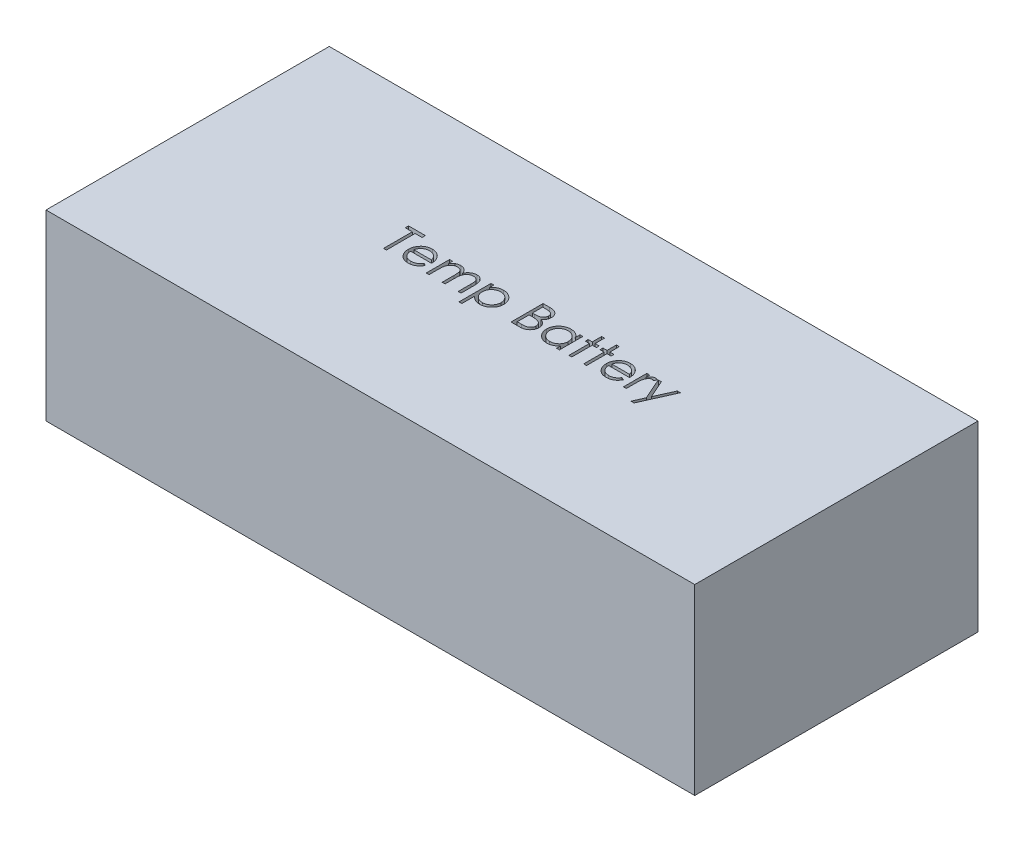
from build123d import *

# Parameters (mm, degrees)
SKETCH1_W           = 71
SKETCH1_H           = 31
BOSS_EXTRUDE1_DEPTH = 20
CUT_EXTRUDE1_DEPTH  = 4


with BuildPart() as part:
    # Sketch1 → Boss-Extrude1 (new body)
    with BuildSketch(Plane(origin=(0, 0, 0), x_dir=(1, 0, 0), z_dir=(0, 1, 0))):
        Rectangle(SKETCH1_W, SKETCH1_H)
    extrude(amount=BOSS_EXTRUDE1_DEPTH)

    # Sketch2 → Cut-Extrude1 (cut)
    with BuildSketch(Plane(origin=(0, 20, 0), x_dir=(1, 0, 0), z_dir=(0, 1, 0))):
        Polygon((-14.152078987, 2.473875698), (-14.152078987, 2.832850057), (-12.312335397, 2.832850057), (-12.312335397, 2.473875698), (-13.07515591, 2.473875698), (-13.07515591, -0.667149943), (-13.389258474, -0.667149943), (-13.389258474, 2.473875698), align=None)
        with BuildLine():
            Line((-9.764458794, 0.140542365), (-9.48541232, -0.00599209))
            add(Edge.make_bspline(
                [(-9.48541232, -0.00599209), (-9.507648915, -0.045435421), (-9.550912524, -0.122176524), (-9.625313271, -0.227608385), (-9.703305344, -0.322456101), (-9.788409312, -0.404185755), (-9.878078991, -0.47543714), (-9.972811646, -0.537774965), (-10.073100464, -0.590893485), (-10.178950188, -0.635646013), (-10.291249739, -0.670055507), (-10.410271256, -0.694359728), (-10.536242751, -0.709382996), (-10.622588931, -0.711128137), (-10.666802544, -0.712021738)],
                knots=[0, 0, 0, 0, 0.000135759, 0.000264133, 0.000386579, 0.000503597, 0.000617365, 0.000729763, 0.000843304, 0.000957371, 0.001074023, 0.001195027, 0.001321389, 0.001453992, 0.001453992, 0.001453992, 0.001453992], degree=3))
            add(Edge.make_bspline(
                [(-10.666802544, -0.712021738), (-10.715944522, -0.710874562), (-10.811806283, -0.708636756), (-10.951346031, -0.689344291), (-11.082725449, -0.657871932), (-11.205937152, -0.613906391), (-11.320679405, -0.556479067), (-11.42718026, -0.486519585), (-11.525999786, -0.40438733), (-11.614023995, -0.309370887), (-11.693267877, -0.20768893), (-11.763193697, -0.101733045), (-11.821651128, 0.008230179), (-11.869203739, 0.121500703), (-11.907608604, 0.237364597), (-11.934375307, 0.356876065), (-11.949805055, 0.479711649), (-11.952169501, 0.562808985), (-11.953361038, 0.604684993)],
                knots=[0, 0, 0, 0, 0.000147371, 0.000287478, 0.000421649, 0.000552053, 0.000679042, 0.000805636, 0.000933558, 0.00106351, 0.001193382, 0.001319977, 0.001443869, 0.001566405, 0.001688128, 0.001809576, 0.001933238, 0.002058864, 0.002058864, 0.002058864, 0.002058864], degree=3))
            add(Edge.make_bspline(
                [(-11.953361038, 0.604684993), (-11.952301896, 0.643979824), (-11.950202818, 0.721856988), (-11.936972031, 0.837122533), (-11.913523738, 0.949150985), (-11.881347414, 1.058035433), (-11.839796168, 1.163593567), (-11.788963948, 1.265889631), (-11.728771571, 1.364814771), (-11.682298897, 1.427217904), (-11.658889884, 1.458651339)],
                knots=[0, 0, 0, 0, 0.000117891, 0.000233644, 0.000347498, 0.000460856, 0.000573868, 0.000687374, 0.000803169, 0.000920699, 0.000920699, 0.000920699, 0.000920699], degree=3))
            add(Edge.make_bspline(
                [(-11.658889884, 1.458651339), (-11.627182201, 1.496520209), (-11.564771255, 1.57105836), (-11.459214899, 1.668996686), (-11.344914703, 1.751040461), (-11.223303077, 1.819047597), (-11.092966603, 1.870721244), (-10.955657312, 1.909228826), (-10.809811725, 1.930806837), (-10.710106505, 1.933854671), (-10.659090204, 1.93541416)],
                knots=[0, 0, 0, 0, 0.000148071, 0.000291452, 0.00043058, 0.000569298, 0.000708346, 0.00085021, 0.000996268, 0.001149307, 0.001149307, 0.001149307, 0.001149307], degree=3))
            add(Edge.make_bspline(
                [(-10.659090204, 1.93541416), (-10.606642599, 1.934060111), (-10.503752353, 1.931403776), (-10.353720232, 1.906777442), (-10.211759516, 1.867724888), (-10.077927011, 1.812571097), (-9.952209151, 1.741411545), (-9.835423101, 1.653269704), (-9.725571588, 1.550851617), (-9.66166301, 1.472088407), (-9.629142288, 1.432008711)],
                knots=[0, 0, 0, 0, 0.000157241, 0.00030847, 0.000454763, 0.000598116, 0.000741606, 0.000886879, 0.001036172, 0.001190853, 0.001190853, 0.001190853, 0.001190853], degree=3))
            add(Edge.make_bspline(
                [(-9.629142288, 1.432008711), (-9.607015349, 1.40180513), (-9.562908756, 1.341599011), (-9.507661656, 1.243427854), (-9.459704261, 1.14071726), (-9.4213713, 1.031806962), (-9.390331799, 0.917987382), (-9.36787498, 0.798444838), (-9.354705362, 0.673214926), (-9.352116664, 0.587888371), (-9.350796935, 0.544388519)],
                knots=[0, 0, 0, 0, 0.000112234, 0.000223721, 0.000337279, 0.000451932, 0.000569628, 0.000690912, 0.000816421, 0.00094695, 0.00094695, 0.00094695, 0.00094695], degree=3))
            Line((-9.350796935, 0.544388519), (-11.639258474, 0.544388519))
            add(Edge.make_bspline(
                [(-11.639258474, 0.544388519), (-11.637718867, 0.510688055), (-11.634691293, 0.444417451), (-11.62057615, 0.347446668), (-11.598327376, 0.255073326), (-11.567058314, 0.167990284), (-11.529191468, 0.085060156), (-11.482805752, 0.006898119), (-11.427466198, -0.066139811), (-11.365740498, -0.134706949), (-11.297033403, -0.19576771), (-11.224750656, -0.250419486), (-11.147857091, -0.296225083), (-11.066959007, -0.333404972), (-10.982187222, -0.362511288), (-10.893515027, -0.382379109), (-10.801116911, -0.395686216), (-10.738131177, -0.397165881), (-10.706065365, -0.397919174)],
                knots=[0, 0, 0, 0, 0.000101159, 0.000198924, 0.000293472, 0.000385722, 0.000476069, 0.000566611, 0.000657757, 0.000750573, 0.000842919, 0.000933083, 0.001022062, 0.001110842, 0.001199752, 0.001290403, 0.001383113, 0.001479259, 0.001479259, 0.001479259, 0.001479259], degree=3))
            add(Edge.make_bspline(
                [(-10.706065365, -0.397919174), (-10.674714217, -0.397311117), (-10.612507526, -0.396104616), (-10.519866669, -0.384372705), (-10.428727141, -0.365402429), (-10.339466158, -0.339512439), (-10.253895312, -0.307935587), (-10.174649762, -0.269832729), (-10.101769547, -0.227682983), (-10.03365258, -0.179473308), (-9.967581587, -0.120465121), (-9.9020391, -0.0468294), (-9.831762447, 0.040258128), (-9.787772854, 0.105803794), (-9.764458794, 0.140542365)],
                knots=[0, 0, 0, 0, 9.4016e-05, 0.000186545, 0.000279636, 0.000373054, 0.000465125, 0.000552934, 0.000636508, 0.000717442, 0.000802858, 0.000901616, 0.001012865, 0.001138311, 0.001138311, 0.001138311, 0.001138311], degree=3))
        make_face()
        with BuildLine():
            add(Edge.make_bspline(
                [(-9.664899499, 0.858491083), (-9.676396124, 0.900153957), (-9.698523425, 0.980341577), (-9.74475979, 1.091382468), (-9.796831331, 1.190070369), (-9.858453062, 1.275650002), (-9.928271788, 1.351653515), (-10.00891697, 1.4180721), (-10.099352864, 1.477489551), (-10.199112004, 1.52764205), (-10.304753789, 1.570331909), (-10.415359981, 1.598957025), (-10.528217769, 1.618566567), (-10.604552056, 1.620392676), (-10.642964403, 1.621311596)],
                knots=[0, 0, 0, 0, 0.000129543, 0.000249328, 0.000360065, 0.000463575, 0.000564789, 0.000668832, 0.000776175, 0.000888744, 0.001003316, 0.001117263, 0.001230914, 0.001346035, 0.001346035, 0.001346035, 0.001346035], degree=3))
            add(Edge.make_bspline(
                [(-10.642964403, 1.621311596), (-10.674313842, 1.620699924), (-10.736285091, 1.619490778), (-10.827586159, 1.608020649), (-10.915265858, 1.589060804), (-10.999971145, 1.563095847), (-11.080592014, 1.528487245), (-11.158786782, 1.487904018), (-11.232567178, 1.438362434), (-11.278708474, 1.40060358), (-11.30201889, 1.381527942)],
                knots=[0, 0, 0, 0, 9.4016e-05, 0.000185849, 0.000275511, 0.000362884, 0.000451173, 0.00053836, 0.000626838, 0.000717174, 0.000717174, 0.000717174, 0.000717174], degree=3))
            add(Edge.make_bspline(
                [(-11.30201889, 1.381527942), (-11.318712172, 1.366433626), (-11.352495307, 1.33588641), (-11.397635828, 1.283257204), (-11.440856301, 1.226505641), (-11.480189953, 1.163460517), (-11.51626754, 1.094839738), (-11.550027517, 1.021222103), (-11.580413929, 0.942048972), (-11.597510039, 0.886876533), (-11.606305749, 0.858491083)],
                knots=[0, 0, 0, 0, 6.7454e-05, 0.00013651, 0.000207604, 0.000281328, 0.000359112, 0.000440057, 0.000524171, 0.000613305, 0.000613305, 0.000613305, 0.000613305], degree=3))
            Line((-11.606305749, 0.858491083), (-9.664899499, 0.858491083))
        make_face(mode=Mode.SUBTRACT)
        with BuildLine():
            Line((-8.722591807, 1.890542365), (-8.408489243, 1.890542365))
            Line((-8.408489243, 1.890542365), (-8.408489243, 1.446031147))
            add(Edge.make_bspline(
                [(-8.408489243, 1.446031147), (-8.380205293, 1.484918749), (-8.326010533, 1.559431122), (-8.237144881, 1.657621406), (-8.148368768, 1.740949561), (-8.084435387, 1.784692432), (-8.053721615, 1.805706628)],
                knots=[0, 0, 0, 0, 0.000144152, 0.000276209, 0.000396804, 0.000508302, 0.000508302, 0.000508302, 0.000508302], degree=3))
            add(Edge.make_bspline(
                [(-8.053721615, 1.805706628), (-8.011856953, 1.825711993), (-7.928859053, 1.865373206), (-7.797439828, 1.905606765), (-7.662965158, 1.930331867), (-7.572156944, 1.93371324), (-7.526478025, 1.93541416)],
                knots=[0, 0, 0, 0, 0.000139031, 0.000275633, 0.000410962, 0.000547939, 0.000547939, 0.000547939, 0.000547939], degree=3))
            add(Edge.make_bspline(
                [(-7.526478025, 1.93541416), (-7.495585028, 1.934368869), (-7.434449449, 1.932300295), (-7.343865359, 1.91884026), (-7.256006747, 1.895574087), (-7.171392718, 1.863166763), (-7.091672039, 1.823920076), (-7.018582841, 1.777870368), (-6.952958633, 1.726173292), (-6.894832582, 1.666494359), (-6.842563556, 1.597157761), (-6.79448471, 1.516293512), (-6.750059497, 1.422085851), (-6.725438188, 1.35371931), (-6.712475621, 1.317725859)],
                knots=[0, 0, 0, 0, 9.2678e-05, 0.000183405, 0.000274048, 0.000364807, 0.000454797, 0.00054019, 0.000623517, 0.000704829, 0.000789387, 0.000883415, 0.000986597, 0.001101318, 0.001101318, 0.001101318, 0.001101318], degree=3))
            add(Edge.make_bspline(
                [(-6.712475621, 1.317725859), (-6.69876437, 1.342450278), (-6.671782553, 1.391104463), (-6.626476916, 1.459962725), (-6.579009119, 1.524369517), (-6.528974626, 1.584375941), (-6.476550039, 1.639685672), (-6.421488639, 1.690481573), (-6.364103857, 1.736981787), (-6.284311618, 1.791304946), (-6.18049901, 1.849006128), (-6.049610895, 1.899034572), (-5.913460724, 1.9299507), (-5.821043026, 1.933580973), (-5.77437466, 1.93541416)],
                knots=[0, 0, 0, 0, 8.4789e-05, 0.000166854, 0.000247064, 0.000324714, 0.000401089, 0.000475513, 0.000549314, 0.000622436, 0.0007649, 0.000904487, 0.001041601, 0.001181469, 0.001181469, 0.001181469, 0.001181469], degree=3))
            add(Edge.make_bspline(
                [(-5.77437466, 1.93541416), (-5.731493197, 1.933796939), (-5.647570011, 1.930631881), (-5.525392745, 1.905778407), (-5.411450939, 1.86310076), (-5.305973863, 1.804867124), (-5.21081405, 1.73168794), (-5.128097741, 1.644619103), (-5.058327377, 1.54427648), (-5.012748738, 1.449884491), (-4.981833473, 1.366549158), (-4.962772239, 1.295542867), (-4.945932544, 1.217391314), (-4.931951299, 1.132001053), (-4.921732747, 1.039070444), (-4.914162031, 0.938751568), (-4.909037958, 0.830966457), (-4.908675885, 0.756600956), (-4.908489243, 0.718266724)],
                knots=[0, 0, 0, 0, 0.000128581, 0.000251645, 0.00037211, 0.000492305, 0.000611786, 0.000730807, 0.000851198, 0.000976936, 0.001044145, 0.001117629, 0.001197252, 0.00128393, 0.001377074, 0.001477631, 0.001585715, 0.001700707, 0.001700707, 0.001700707, 0.001700707], degree=3))
            Line((-4.908489243, 0.718266724), (-4.908489243, -0.667149943))
            Line((-4.908489243, -0.667149943), (-5.222591807, -0.667149943))
            Line((-5.222591807, -0.667149943), (-5.222591807, 0.719668968))
            add(Edge.make_bspline(
                [(-5.222591807, 0.719668968), (-5.22266969, 0.752389541), (-5.222819369, 0.815273508), (-5.225513001, 0.90552596), (-5.230588315, 0.987794317), (-5.236522954, 1.061966405), (-5.244766763, 1.128215193), (-5.255412695, 1.186407612), (-5.266690375, 1.237001423), (-5.285426366, 1.293087471), (-5.315374257, 1.354957681), (-5.360991737, 1.421681257), (-5.418461844, 1.479762057), (-5.484822, 1.530180374), (-5.560370445, 1.571174015), (-5.643635168, 1.600450025), (-5.73409922, 1.618572903), (-5.796722008, 1.620378919), (-5.82906216, 1.621311596)],
                knots=[0, 0, 0, 0, 9.816e-05, 0.000188648, 0.000270826, 0.000345412, 0.000411852, 0.000470988, 0.000522857, 0.0005672, 0.000648106, 0.000728233, 0.000808554, 0.000892128, 0.000977461, 0.001065278, 0.001156029, 0.001252946, 0.001252946, 0.001252946, 0.001252946], degree=3))
            add(Edge.make_bspline(
                [(-5.82906216, 1.621311596), (-5.868732114, 1.619895438), (-5.947135025, 1.617096573), (-6.061580511, 1.5885227), (-6.171551528, 1.545442449), (-6.273766661, 1.483009992), (-6.367794451, 1.408201628), (-6.448694029, 1.319252033), (-6.515526215, 1.218622106), (-6.560780191, 1.125475403), (-6.589369492, 1.041805959), (-6.608246408, 0.968708587), (-6.622929799, 0.88562702), (-6.636700329, 0.793119529), (-6.645688057, 0.690549348), (-6.653856429, 0.578390947), (-6.657677292, 0.456306988), (-6.65821175, 0.371680299), (-6.658489243, 0.327741884)],
                knots=[0, 0, 0, 0, 0.000118788, 0.00023477, 0.000351815, 0.000471937, 0.000592603, 0.000711217, 0.000831002, 0.000953929, 0.001020668, 0.001096002, 0.00118016, 0.001273662, 0.001376495, 0.001488939, 0.001611007, 0.001742825, 0.001742825, 0.001742825, 0.001742825], degree=3))
            Line((-6.658489243, 0.327741884), (-6.658489243, -0.667149943))
            Line((-6.658489243, -0.667149943), (-6.972591807, -0.667149943))
            Line((-6.972591807, -0.667149943), (-6.972591807, 0.633430987))
            add(Edge.make_bspline(
                [(-6.972591807, 0.633430987), (-6.972671238, 0.670124306), (-6.972824055, 0.740718563), (-6.975500373, 0.841952238), (-6.980586994, 0.934033318), (-6.986467543, 1.016854782), (-6.994927721, 1.090266111), (-7.004537483, 1.154660869), (-7.015886094, 1.20987762), (-7.034675978, 1.270441005), (-7.063390447, 1.337161928), (-7.109578709, 1.408302949), (-7.167186289, 1.470571046), (-7.234757165, 1.523729795), (-7.310762847, 1.567671276), (-7.394746248, 1.599331028), (-7.485951161, 1.617755317), (-7.548828867, 1.620103814), (-7.581165525, 1.621311596)],
                knots=[0, 0, 0, 0, 0.000110078, 0.00021178, 0.000303758, 0.00038673, 0.000460827, 0.00052538, 0.000582037, 0.000629718, 0.00071543, 0.000799052, 0.000882908, 0.000968755, 0.001056067, 0.001145266, 0.001236843, 0.001333803, 0.001333803, 0.001333803, 0.001333803], degree=3))
            add(Edge.make_bspline(
                [(-7.581165525, 1.621311596), (-7.619181736, 1.619781136), (-7.694946696, 1.616730983), (-7.806248665, 1.589276709), (-7.913734349, 1.546272635), (-8.015689048, 1.486612816), (-8.109363196, 1.412713737), (-8.191371463, 1.325798841), (-8.260313989, 1.226949808), (-8.306045804, 1.134785291), (-8.335544278, 1.053212016), (-8.355139613, 0.983861069), (-8.371979239, 0.90686082), (-8.38449326, 0.821973709), (-8.396573676, 0.729752615), (-8.402403985, 0.629738125), (-8.408075547, 0.522016038), (-8.408347962, 0.447643492), (-8.408489243, 0.409072012)],
                knots=[0, 0, 0, 0, 0.000113893, 0.000226985, 0.000341817, 0.000460265, 0.000580056, 0.000698595, 0.000817435, 0.000940348, 0.001005999, 0.001077458, 0.001156396, 0.001242271, 0.001334801, 0.001435306, 0.00154269, 0.001658383, 0.001658383, 0.001658383, 0.001658383], degree=3))
            Line((-8.408489243, 0.409072012), (-8.408489243, -0.667149943))
            Line((-8.408489243, -0.667149943), (-8.722591807, -0.667149943))
            Line((-8.722591807, -0.667149943), (-8.722591807, 1.890542365))
        make_face()
        with BuildLine():
            Line((-4.190540525, 1.890542365), (-3.876437961, 1.890542365))
            Line((-3.876437961, 1.890542365), (-3.876437961, 1.417285153))
            add(Edge.make_bspline(
                [(-3.876437961, 1.417285153), (-3.843080477, 1.460222887), (-3.778256882, 1.54366378), (-3.666531977, 1.651653909), (-3.548605168, 1.742729212), (-3.421441756, 1.814111745), (-3.287018066, 1.867932557), (-3.145885748, 1.907712007), (-2.996846983, 1.931153482), (-2.894950531, 1.933975143), (-2.842984435, 1.93541416)],
                knots=[0, 0, 0, 0, 0.00016294, 0.00031664, 0.000464722, 0.000608822, 0.000752559, 0.000898176, 0.001047911, 0.001203751, 0.001203751, 0.001203751, 0.001203751], degree=3))
            add(Edge.make_bspline(
                [(-2.842984435, 1.93541416), (-2.797592832, 1.934100981), (-2.707873944, 1.931505414), (-2.575810715, 1.913932359), (-2.448635331, 1.883814667), (-2.327067277, 1.840413752), (-2.209804212, 1.786758282), (-2.098582112, 1.719041246), (-1.991668557, 1.640635055), (-1.891752368, 1.550402904), (-1.799431, 1.452774638), (-1.719584819, 1.347752334), (-1.650712915, 1.238789747), (-1.595042618, 1.124197655), (-1.551434271, 1.004878425), (-1.520419593, 0.880349984), (-1.50196195, 0.751074044), (-1.499485498, 0.663171323), (-1.498232833, 0.618707429)],
                knots=[0, 0, 0, 0, 0.000136164, 0.000269135, 0.000398888, 0.000527501, 0.000655799, 0.000785059, 0.000917435, 0.001052984, 0.001188402, 0.001319939, 0.001448139, 0.001574506, 0.001701376, 0.001828571, 0.001958859, 0.002092222, 0.002092222, 0.002092222, 0.002092222], degree=3))
            add(Edge.make_bspline(
                [(-1.498232833, 0.618707429), (-1.499458318, 0.573305121), (-1.501875153, 0.483765216), (-1.520620159, 0.352278119), (-1.550577033, 0.225790745), (-1.593635216, 0.104513481), (-1.649276704, -0.01147017), (-1.716981265, -0.122076566), (-1.796867732, -0.227270269), (-1.888168859, -0.325623169), (-1.987221795, -0.416222482), (-2.093099285, -0.495460552), (-2.20415821, -0.562001927), (-2.319830378, -0.617584887), (-2.441106016, -0.659477071), (-2.567419294, -0.689694871), (-2.69870144, -0.708329367), (-2.788002592, -0.710781509), (-2.83316873, -0.712021738)],
                knots=[0, 0, 0, 0, 0.000136164, 0.000268535, 0.000397606, 0.000525558, 0.00065382, 0.000782843, 0.000913955, 0.001049409, 0.001184907, 0.001316158, 0.001445417, 0.001572744, 0.001700463, 0.001829535, 0.001961906, 0.002097369, 0.002097369, 0.002097369, 0.002097369], degree=3))
            add(Edge.make_bspline(
                [(-2.83316873, -0.712021738), (-2.883996302, -0.71072693), (-2.984395658, -0.708169305), (-3.131193329, -0.682249895), (-3.27247018, -0.643512959), (-3.406661005, -0.586813966), (-3.534828818, -0.51455845), (-3.656248623, -0.426448244), (-3.771565376, -0.322667619), (-3.840974134, -0.243935803), (-3.876437961, -0.203708436)],
                knots=[0, 0, 0, 0, 0.000152339, 0.000300914, 0.000445856, 0.000591043, 0.000736709, 0.000886352, 0.001040245, 0.001201023, 0.001201023, 0.001201023, 0.001201023], degree=3))
            Line((-3.876437961, -0.203708436), (-3.876437961, -1.609457635))
            Line((-3.876437961, -1.609457635), (-4.190540525, -1.609457635))
            Line((-4.190540525, -1.609457635), (-4.190540525, 1.890542365))
        make_face()
        with BuildLine():
            add(Edge.make_bspline(
                [(-2.845788922, 1.621311596), (-2.881368485, 1.620671338), (-2.951415473, 1.619410834), (-3.054087692, 1.604436885), (-3.152983119, 1.582699144), (-3.247105071, 1.549787244), (-3.337355687, 1.509388431), (-3.423039852, 1.45890642), (-3.50409742, 1.399254414), (-3.58032445, 1.33157507), (-3.649187743, 1.257000382), (-3.710150671, 1.177412573), (-3.761357977, 1.092912433), (-3.803859997, 1.00428707), (-3.836203279, 0.910841785), (-3.859158999, 0.813108773), (-3.873589352, 0.71098106), (-3.875478289, 0.641425054), (-3.876437961, 0.606087237)],
                knots=[0, 0, 0, 0, 0.000106654, 0.000209973, 0.000310662, 0.000409994, 0.000508521, 0.000606883, 0.00070771, 0.000810012, 0.000912217, 0.001011779, 0.001110258, 0.001208104, 0.001306111, 0.001406276, 0.001508901, 0.001614884, 0.001614884, 0.001614884, 0.001614884], degree=3))
            add(Edge.make_bspline(
                [(-3.876437961, 0.606087237), (-3.874847105, 0.559699124), (-3.871730483, 0.468820883), (-3.846393115, 0.336036761), (-3.805157851, 0.210385106), (-3.746629137, 0.092924069), (-3.672681563, -0.015058767), (-3.583583407, -0.111749373), (-3.480140856, -0.196539964), (-3.364073664, -0.267961218), (-3.239651533, -0.325949284), (-3.109865621, -0.367463495), (-2.97650074, -0.393035723), (-2.886332421, -0.396282542), (-2.84088107, -0.397919174)],
                knots=[0, 0, 0, 0, 0.000139077, 0.000272463, 0.00040394, 0.000534691, 0.000664794, 0.000795295, 0.000927798, 0.001064768, 0.001203104, 0.001338581, 0.001472656, 0.001608934, 0.001608934, 0.001608934, 0.001608934], degree=3))
            add(Edge.make_bspline(
                [(-2.84088107, -0.397919174), (-2.796345302, -0.396362797), (-2.707949809, -0.393273668), (-2.577791687, -0.366535481), (-2.451301049, -0.325690456), (-2.331120877, -0.2661309), (-2.218297389, -0.193140842), (-2.116415835, -0.105580809), (-2.027408922, -0.004090865), (-1.951544567, 0.108917638), (-1.890413081, 0.230093021), (-1.844482841, 0.35547441), (-1.817974268, 0.484619833), (-1.81421748, 0.571617546), (-1.812335397, 0.61520182)],
                knots=[0, 0, 0, 0, 0.000133479, 0.000264931, 0.000397073, 0.000531279, 0.000666044, 0.000799279, 0.000932907, 0.001069805, 0.001206515, 0.001339137, 0.001469351, 0.001600078, 0.001600078, 0.001600078, 0.001600078], degree=3))
            add(Edge.make_bspline(
                [(-1.812335397, 0.61520182), (-1.813790131, 0.659056809), (-1.816688264, 0.746425113), (-1.845235302, 0.875188016), (-1.88813528, 1.001075992), (-1.950694332, 1.120596542), (-2.024895601, 1.233370624), (-2.114642598, 1.332924503), (-2.215258795, 1.420095176), (-2.327947959, 1.492110586), (-2.448888384, 1.549396081), (-2.5762033, 1.59127972), (-2.709246902, 1.616453469), (-2.799874557, 1.619677976), (-2.845788922, 1.621311596)],
                knots=[0, 0, 0, 0, 0.000131379, 0.000261735, 0.000393889, 0.000529349, 0.000665274, 0.000797853, 0.0009301, 0.001063514, 0.001197743, 0.001330552, 0.001464627, 0.001602305, 0.001602305, 0.001602305, 0.001602305], degree=3))
        make_face(mode=Mode.SUBTRACT)
        with BuildLine():
            Line((0.565869731, 2.832850057), (1.24876236, 2.832850057))
            add(Edge.make_bspline(
                [(1.24876236, 2.832850057), (1.282190838, 2.832674307), (1.346983548, 2.832333659), (1.44120299, 2.827050528), (1.529451801, 2.819846858), (1.611755573, 2.808416765), (1.688076275, 2.794624988), (1.758643913, 2.777923172), (1.823234085, 2.757896558), (1.900346821, 2.726050277), (1.988267482, 2.678727109), (2.083465875, 2.608798544), (2.164870114, 2.52326608), (2.235056431, 2.426783425), (2.290857551, 2.320647653), (2.331226848, 2.207388464), (2.356784724, 2.088466723), (2.359413158, 2.006823545), (2.360741526, 1.965562397)],
                knots=[0, 0, 0, 0, 0.00010027, 0.000194349, 0.000283026, 0.000365821, 0.000443519, 0.000515622, 0.000583254, 0.00064614, 0.000765662, 0.000881909, 0.000998927, 0.001118415, 0.001238844, 0.00135727, 0.001478274, 0.001601912, 0.001601912, 0.001601912, 0.001601912], degree=3))
            add(Edge.make_bspline(
                [(2.360741526, 1.965562397), (2.359648308, 1.926909841), (2.357500031, 1.850953924), (2.336957271, 1.739859815), (2.304796603, 1.634108596), (2.260091354, 1.534086211), (2.201989357, 1.442052598), (2.133131039, 1.357265332), (2.050054236, 1.283314275), (1.987810996, 1.241971372), (1.956194251, 1.220971051)],
                knots=[0, 0, 0, 0, 0.000115857, 0.00022767, 0.000337672, 0.000446877, 0.000555233, 0.000663318, 0.000773539, 0.000887324, 0.000887324, 0.000887324, 0.000887324], degree=3))
            add(Edge.make_bspline(
                [(1.956194251, 1.220971051), (1.995954678, 1.205706052), (2.072026226, 1.176500328), (2.176712238, 1.124864864), (2.266907083, 1.068702753), (2.343304229, 1.007370903), (2.408641884, 0.941262092), (2.465694826, 0.869406978), (2.5143762, 0.79086822), (2.556089123, 0.706464685), (2.588637879, 0.617058216), (2.613013784, 0.52348744), (2.626981233, 0.426087885), (2.628968874, 0.359802506), (2.629972296, 0.326339641)],
                knots=[0, 0, 0, 0, 0.000127722, 0.000244363, 0.000349599, 0.000445847, 0.000537565, 0.000627901, 0.000720503, 0.000814257, 0.000909859, 0.001005428, 0.001103887, 0.001204268, 0.001204268, 0.001204268, 0.001204268], degree=3))
            add(Edge.make_bspline(
                [(2.629972296, 0.326339641), (2.62899545, 0.292172768), (2.627073478, 0.22494849), (2.612893506, 0.126193356), (2.588884399, 0.031818409), (2.555813252, -0.058786773), (2.512650938, -0.145446908), (2.460122974, -0.228260172), (2.39749141, -0.306394503), (2.327428541, -0.380718126), (2.248166395, -0.447545913), (2.162650641, -0.50706162), (2.069804321, -0.556007682), (1.971152327, -0.597123703), (1.865588011, -0.628530902), (1.753585403, -0.650503476), (1.635241101, -0.665308513), (1.55403135, -0.666525718), (1.512384155, -0.667149943)],
                knots=[0, 0, 0, 0, 0.000102481, 0.000201635, 0.000298562, 0.000394165, 0.000490425, 0.000588455, 0.000687769, 0.000790423, 0.000894381, 0.000998232, 0.001102369, 0.001208616, 0.001318415, 0.001432129, 0.001550749, 0.00167562, 0.00167562, 0.00167562, 0.00167562], degree=3))
            Line((1.512384155, -0.667149943), (0.565869731, -0.667149943))
            Line((0.565869731, -0.667149943), (0.565869731, 2.832850057))
        make_face()
        with BuildLine():
            Line((0.879972296, 2.473875698), (0.879972296, 1.352080826))
            Line((0.879972296, 1.352080826), (1.091009956, 1.352080826))
            add(Edge.make_bspline(
                [(1.091009956, 1.352080826), (1.121858751, 1.35248075), (1.18146491, 1.353253482), (1.267784807, 1.355466999), (1.347909825, 1.361665043), (1.421701658, 1.367861305), (1.489044102, 1.377935892), (1.549787964, 1.389928015), (1.604886561, 1.40261092), (1.668426106, 1.424180407), (1.740499055, 1.456058083), (1.817332159, 1.505529919), (1.885066628, 1.564454272), (1.942263816, 1.632445234), (1.989075287, 1.707311419), (2.021589002, 1.7878583), (2.043636286, 1.872078432), (2.045627817, 1.929896685), (2.046638962, 1.959252301)],
                knots=[0, 0, 0, 0, 9.2559e-05, 0.000178842, 0.000258967, 0.000333616, 0.000400942, 0.000463093, 0.000519379, 0.000570374, 0.000664201, 0.000755025, 0.000843472, 0.000932526, 0.001020669, 0.001107124, 0.001192318, 0.001280185, 0.001280185, 0.001280185, 0.001280185], degree=3))
            add(Edge.make_bspline(
                [(2.046638962, 1.959252301), (2.046112782, 1.978678072), (2.045080622, 2.016783844), (2.03662732, 2.072333199), (2.022259745, 2.124576951), (2.003805452, 2.174231061), (1.978016763, 2.219742912), (1.9476533, 2.262686107), (1.91096761, 2.301598226), (1.869210297, 2.337967724), (1.821201674, 2.370212252), (1.766970382, 2.398453015), (1.705782705, 2.421193792), (1.63866985, 2.441109944), (1.564598763, 2.455098238), (1.484424209, 2.466751626), (1.39748949, 2.472684368), (1.337344388, 2.473469731), (1.306254347, 2.473875698)],
                knots=[0, 0, 0, 0, 5.8261e-05, 0.000114285, 0.000168029, 0.000220632, 0.000272728, 0.000324483, 0.000378062, 0.000432741, 0.000490301, 0.000551137, 0.000615721, 0.000685833, 0.000760908, 0.00084162, 0.000928788, 0.00102206, 0.00102206, 0.00102206, 0.00102206], degree=3))
            Line((1.306254347, 2.473875698), (0.879972296, 2.473875698))
        make_face(mode=Mode.SUBTRACT)
        with BuildLine():
            Line((0.879972296, 0.993106468), (0.879972296, -0.308175584))
            Line((0.879972296, -0.308175584), (1.327288001, -0.308175584))
            add(Edge.make_bspline(
                [(1.327288001, -0.308175584), (1.359306927, -0.307791836), (1.421019185, -0.307052214), (1.510120415, -0.304637659), (1.592703519, -0.299145384), (1.668391655, -0.290499534), (1.738002107, -0.281121085), (1.80069981, -0.268509804), (1.856993004, -0.254060843), (1.922267312, -0.231726671), (1.99577082, -0.1970302), (2.074981676, -0.144715974), (2.145407894, -0.082392666), (2.205213154, -0.010261752), (2.254226142, 0.068169575), (2.289881597, 0.151314925), (2.311872454, 0.237800453), (2.314534623, 0.296767165), (2.315869731, 0.326339641)],
                knots=[0, 0, 0, 0, 9.6064e-05, 0.000185151, 0.000267373, 0.000344257, 0.000413665, 0.000478015, 0.000536005, 0.000587888, 0.000684801, 0.000778918, 0.000871787, 0.000965866, 0.001059062, 0.00114827, 0.001236355, 0.001324974, 0.001324974, 0.001324974, 0.001324974], degree=3))
            add(Edge.make_bspline(
                [(2.315869731, 0.326339641), (2.315593627, 0.344832981), (2.315045872, 0.381521363), (2.306785257, 0.435437182), (2.294771387, 0.487663055), (2.279239953, 0.538340796), (2.256620486, 0.586554172), (2.230213941, 0.633256732), (2.19925254, 0.678510211), (2.151008374, 0.735722465), (2.080836389, 0.801639478), (1.981129614, 0.86617698), (1.867757316, 0.918224787), (1.785529823, 0.940324263), (1.743053225, 0.951740282)],
                knots=[0, 0, 0, 0, 5.5429e-05, 0.000109963, 0.000163198, 0.000216191, 0.000268588, 0.000322593, 0.000377046, 0.000432793, 0.000546889, 0.000664343, 0.000787646, 0.000919405, 0.000919405, 0.000919405, 0.000919405], degree=3))
            add(Edge.make_bspline(
                [(1.743053225, 0.951740282), (1.726024129, 0.955195366), (1.689101537, 0.9626867), (1.628893956, 0.970594404), (1.560158088, 0.977639464), (1.48273521, 0.982850621), (1.396527369, 0.988237165), (1.30135045, 0.990331986), (1.197593136, 0.992831246), (1.125600763, 0.99301238), (1.088205469, 0.993106468)],
                knots=[0, 0, 0, 0, 5.2115e-05, 0.000112995, 0.000182062, 0.000259389, 0.000345767, 0.00044116, 0.000544948, 0.000657129, 0.000657129, 0.000657129, 0.000657129], degree=3))
            Line((1.088205469, 0.993106468), (0.879972296, 0.993106468))
        make_face(mode=Mode.SUBTRACT)
        with BuildLine():
            Line((5.860741526, 1.890542365), (5.860741526, -0.667149943))
            Line((5.860741526, -0.667149943), (5.546638962, -0.667149943))
            Line((5.546638962, -0.667149943), (5.546638962, -0.22474209))
            add(Edge.make_bspline(
                [(5.546638962, -0.22474209), (5.511220172, -0.264781684), (5.442099956, -0.342919455), (5.326658838, -0.445001628), (5.20429066, -0.529379949), (5.075589339, -0.597529865), (4.940671096, -0.648721921), (4.799835009, -0.68510808), (4.653023628, -0.708501916), (4.552771273, -0.710837937), (4.501967488, -0.712021738)],
                knots=[0, 0, 0, 0, 0.000160263, 0.000312755, 0.000460949, 0.000605216, 0.000748578, 0.000892786, 0.001041028, 0.001193333, 0.001193333, 0.001193333, 0.001193333], degree=3))
            add(Edge.make_bspline(
                [(4.501967488, -0.712021738), (4.456799534, -0.710795365), (4.367726329, -0.708376905), (4.236697252, -0.689614601), (4.110605003, -0.65948398), (3.98933043, -0.61758309), (3.873658284, -0.562002269), (3.762598188, -0.49546102), (3.656725496, -0.41622019), (3.557653957, -0.325632162), (3.466421956, -0.227237175), (3.386360684, -0.122291628), (3.319607604, -0.011249324), (3.263787523, 0.10448383), (3.220791179, 0.225798749), (3.190817545, 0.352275917), (3.172077098, 0.483765791), (3.169659637, 0.573305314), (3.168433834, 0.618707429)],
                knots=[0, 0, 0, 0, 0.000135464, 0.00026714, 0.000396211, 0.000523931, 0.000651257, 0.000780517, 0.000911767, 0.001047265, 0.00118272, 0.001313831, 0.001442491, 0.001570752, 0.001698704, 0.001827775, 0.001960146, 0.00209631, 0.00209631, 0.00209631, 0.00209631], degree=3))
            add(Edge.make_bspline(
                [(3.168433834, 0.618707429), (3.169686805, 0.663171133), (3.172163862, 0.751073476), (3.190617082, 0.880352174), (3.221648091, 1.004870435), (3.265195938, 1.124227378), (3.321037893, 1.238567428), (3.38896598, 1.347971453), (3.468985105, 1.452740851), (3.561237512, 1.550412077), (3.661172282, 1.640632692), (3.768081013, 1.719041737), (3.879304294, 1.786758586), (3.996567305, 1.840412062), (4.11813441, 1.883821167), (4.245087856, 1.913854135), (4.376899434, 1.931551456), (4.466389926, 1.93411422), (4.511783193, 1.93541416)],
                knots=[0, 0, 0, 0, 0.000133363, 0.00026365, 0.000390846, 0.000517716, 0.000644083, 0.000771912, 0.000903449, 0.001038867, 0.001174416, 0.001306792, 0.001436052, 0.00156435, 0.001692963, 0.001822716, 0.001954992, 0.002091156, 0.002091156, 0.002091156, 0.002091156], degree=3))
            add(Edge.make_bspline(
                [(4.511783193, 1.93541416), (4.563983052, 1.933976408), (4.666344512, 1.931157045), (4.816072521, 1.907694318), (4.957716999, 1.868055851), (5.092371351, 1.814138353), (5.219552037, 1.742489624), (5.338055022, 1.652109663), (5.449120505, 1.543568476), (5.513500797, 1.460198031), (5.546638962, 1.417285153)],
                knots=[0, 0, 0, 0, 0.00015654, 0.000306968, 0.000453261, 0.000596998, 0.000741098, 0.000889738, 0.001042937, 0.001205434, 0.001205434, 0.001205434, 0.001205434], degree=3))
            Line((5.546638962, 1.417285153), (5.546638962, 1.890542365))
            Line((5.546638962, 1.890542365), (5.860741526, 1.890542365))
        make_face()
        with BuildLine():
            add(Edge.make_bspline(
                [(4.515989924, 1.621311596), (4.470075586, 1.619677958), (4.379447986, 1.616453417), (4.246403984, 1.591279922), (4.11909057, 1.549395327), (3.998144495, 1.492113426), (3.885476279, 1.42008469), (3.784782608, 1.332963306), (3.695239907, 1.233126292), (3.619931642, 1.121024182), (3.558541146, 1.000846091), (3.515374114, 0.875221653), (3.486904866, 0.746416675), (3.483996346, 0.659053989), (3.482536398, 0.61520182)],
                knots=[0, 0, 0, 0, 0.000137677, 0.000271753, 0.000404561, 0.000538791, 0.000672205, 0.000804452, 0.00093703, 0.001073348, 0.00120849, 0.001340643, 0.001470999, 0.001602378, 0.001602378, 0.001602378, 0.001602378], degree=3))
            add(Edge.make_bspline(
                [(3.482536398, 0.61520182), (3.484401291, 0.571611713), (3.488123768, 0.484602357), (3.514874463, 0.35562178), (3.559754336, 0.229967738), (3.620996399, 0.108706745), (3.697683024, -0.003877356), (3.786571676, -0.105617478), (3.888521957, -0.193107067), (4.001449465, -0.26634464), (4.122057435, -0.325507161), (4.248891366, -0.366672801), (4.379567005, -0.393250581), (4.468419338, -0.396355058), (4.513185437, -0.397919174)],
                knots=[0, 0, 0, 0, 0.000130727, 0.000260941, 0.000393327, 0.000530037, 0.000667328, 0.000800955, 0.000934191, 0.001068956, 0.001203792, 0.001335934, 0.001468075, 0.001602253, 0.001602253, 0.001602253, 0.001602253], degree=3))
            add(Edge.make_bspline(
                [(4.513185437, -0.397919174), (4.558631939, -0.39625921), (4.649020526, -0.392957706), (4.782459234, -0.367676441), (4.911954197, -0.325907642), (5.035741425, -0.268008516), (5.151057556, -0.19625116), (5.254555434, -0.112244069), (5.342071402, -0.014540885), (5.416264012, 0.092835569), (5.474439428, 0.210547565), (5.516815488, 0.335881756), (5.541869393, 0.468842504), (5.545027123, 0.559706431), (5.546638962, 0.606087237)],
                knots=[0, 0, 0, 0, 0.000136278, 0.000271043, 0.000405851, 0.000543552, 0.000679927, 0.000812429, 0.000941985, 0.001072088, 0.00120284, 0.001334538, 0.001467925, 0.001607002, 0.001607002, 0.001607002, 0.001607002], degree=3))
            add(Edge.make_bspline(
                [(5.546638962, 0.606087237), (5.545679306, 0.641425067), (5.543790398, 0.710981101), (5.529359829, 0.813108618), (5.506404902, 0.910842344), (5.474058732, 1.004285033), (5.431567448, 1.092920049), (5.380319682, 1.177383809), (5.319414232, 1.25723702), (5.249831536, 1.331380091), (5.173666334, 1.399006554), (5.093071793, 1.459370794), (5.007093046, 1.508959567), (4.917176009, 1.550000838), (4.823164675, 1.582659988), (4.724294055, 1.604447682), (4.621615068, 1.619408003), (4.551569013, 1.620670384), (4.515989924, 1.621311596)],
                knots=[0, 0, 0, 0, 0.000105983, 0.000208608, 0.000308773, 0.00040678, 0.000504626, 0.000603105, 0.000702667, 0.00080535, 0.000907651, 0.001007914, 0.001106881, 0.00120477, 0.001304102, 0.001404791, 0.00150811, 0.001614764, 0.001614764, 0.001614764, 0.001614764], degree=3))
        make_face(mode=Mode.SUBTRACT)
        Polygon((6.892792808, 2.922593647), (7.206895372, 2.922593647), (7.206895372, 1.890542365), (7.655613321, 1.890542365), (7.655613321, 1.576439801), (7.206895372, 1.576439801), (7.206895372, -0.667149943), (6.892792808, -0.667149943), (6.892792808, 1.576439801), (6.44407486, 1.576439801), (6.44407486, 1.890542365), (6.892792808, 1.890542365), align=None)
        Polygon((8.508177424, 2.922593647), (8.822279988, 2.922593647), (8.822279988, 1.890542365), (9.270997937, 1.890542365), (9.270997937, 1.576439801), (8.822279988, 1.576439801), (8.822279988, -0.667149943), (8.508177424, -0.667149943), (8.508177424, 1.576439801), (8.059459475, 1.576439801), (8.059459475, 1.890542365), (8.508177424, 1.890542365), align=None)
        with BuildLine():
            Line((11.908618129, 0.140542365), (12.187664603, -0.00599209))
            add(Edge.make_bspline(
                [(12.187664603, -0.00599209), (12.165428008, -0.045435421), (12.1221644, -0.122176524), (12.047763652, -0.227608385), (11.969771579, -0.322456101), (11.884667611, -0.404185755), (11.794997932, -0.47543714), (11.700265277, -0.537774965), (11.59997646, -0.590893485), (11.494126735, -0.635646013), (11.381827184, -0.670055507), (11.262805667, -0.694359728), (11.136834172, -0.709382996), (11.050487992, -0.711128137), (11.006274379, -0.712021738)],
                knots=[0, 0, 0, 0, 0.000135759, 0.000264133, 0.000386579, 0.000503597, 0.000617365, 0.000729763, 0.000843304, 0.000957371, 0.001074023, 0.001195027, 0.001321389, 0.001453992, 0.001453992, 0.001453992, 0.001453992], degree=3))
            add(Edge.make_bspline(
                [(11.006274379, -0.712021738), (10.957132401, -0.710874562), (10.86127064, -0.708636756), (10.721730893, -0.689344291), (10.590351474, -0.657871932), (10.467139771, -0.613906391), (10.352397518, -0.556479067), (10.245896663, -0.486519585), (10.147077138, -0.40438733), (10.059052928, -0.309370887), (9.979809046, -0.20768893), (9.909883226, -0.101733045), (9.851425795, 0.008230179), (9.803873184, 0.121500703), (9.765468319, 0.237364597), (9.738701616, 0.356876065), (9.723271868, 0.479711649), (9.720907422, 0.562808985), (9.719715885, 0.604684993)],
                knots=[0, 0, 0, 0, 0.000147371, 0.000287478, 0.000421649, 0.000552053, 0.000679042, 0.000805636, 0.000933558, 0.00106351, 0.001193382, 0.001319977, 0.001443869, 0.001566405, 0.001688128, 0.001809576, 0.001933238, 0.002058864, 0.002058864, 0.002058864, 0.002058864], degree=3))
            add(Edge.make_bspline(
                [(9.719715885, 0.604684993), (9.720775027, 0.643979824), (9.722874105, 0.721856988), (9.736104892, 0.837122533), (9.759553185, 0.949150985), (9.791729509, 1.058035433), (9.833280755, 1.163593567), (9.884112975, 1.265889631), (9.944305352, 1.364814771), (9.990778026, 1.427217904), (10.014187039, 1.458651339)],
                knots=[0, 0, 0, 0, 0.000117891, 0.000233644, 0.000347498, 0.000460856, 0.000573868, 0.000687374, 0.000803169, 0.000920699, 0.000920699, 0.000920699, 0.000920699], degree=3))
            add(Edge.make_bspline(
                [(10.014187039, 1.458651339), (10.045894722, 1.496520209), (10.108305669, 1.57105836), (10.213862024, 1.668996686), (10.32816222, 1.751040461), (10.449773846, 1.819047597), (10.58011032, 1.870721244), (10.717419611, 1.909228826), (10.863265198, 1.930806837), (10.962970418, 1.933854671), (11.013986719, 1.93541416)],
                knots=[0, 0, 0, 0, 0.000148071, 0.000291452, 0.00043058, 0.000569298, 0.000708346, 0.00085021, 0.000996268, 0.001149307, 0.001149307, 0.001149307, 0.001149307], degree=3))
            add(Edge.make_bspline(
                [(11.013986719, 1.93541416), (11.066434324, 1.934060111), (11.16932457, 1.931403776), (11.319356691, 1.906777442), (11.461317407, 1.867724888), (11.595149912, 1.812571097), (11.720867773, 1.741411545), (11.837653822, 1.653269704), (11.947505335, 1.550851617), (12.011413913, 1.472088407), (12.043934635, 1.432008711)],
                knots=[0, 0, 0, 0, 0.000157241, 0.00030847, 0.000454763, 0.000598116, 0.000741606, 0.000886879, 0.001036172, 0.001190853, 0.001190853, 0.001190853, 0.001190853], degree=3))
            add(Edge.make_bspline(
                [(12.043934635, 1.432008711), (12.066061574, 1.40180513), (12.110168167, 1.341599011), (12.165415267, 1.243427854), (12.213372662, 1.14071726), (12.251705623, 1.031806962), (12.282745124, 0.917987382), (12.305201943, 0.798444838), (12.318371561, 0.673214926), (12.320960259, 0.587888371), (12.322279988, 0.544388519)],
                knots=[0, 0, 0, 0, 0.000112234, 0.000223721, 0.000337279, 0.000451932, 0.000569628, 0.000690912, 0.000816421, 0.00094695, 0.00094695, 0.00094695, 0.00094695], degree=3))
            Line((12.322279988, 0.544388519), (10.033818449, 0.544388519))
            add(Edge.make_bspline(
                [(10.033818449, 0.544388519), (10.035358056, 0.510688055), (10.03838563, 0.444417451), (10.052500773, 0.347446668), (10.074749547, 0.255073326), (10.106018609, 0.167990284), (10.143885455, 0.085060156), (10.190271171, 0.006898119), (10.245610725, -0.066139811), (10.307336425, -0.134706949), (10.37604352, -0.19576771), (10.448326267, -0.250419486), (10.525219832, -0.296225083), (10.606117916, -0.333404972), (10.690889701, -0.362511288), (10.779561896, -0.382379109), (10.871960012, -0.395686216), (10.934945746, -0.397165881), (10.967011558, -0.397919174)],
                knots=[0, 0, 0, 0, 0.000101159, 0.000198924, 0.000293472, 0.000385722, 0.000476069, 0.000566611, 0.000657757, 0.000750573, 0.000842919, 0.000933083, 0.001022062, 0.001110842, 0.001199752, 0.001290403, 0.001383113, 0.001479259, 0.001479259, 0.001479259, 0.001479259], degree=3))
            add(Edge.make_bspline(
                [(10.967011558, -0.397919174), (10.998362706, -0.397311117), (11.060569397, -0.396104616), (11.153210254, -0.384372705), (11.244349782, -0.365402429), (11.333610765, -0.339512439), (11.419181611, -0.307935587), (11.498427161, -0.269832729), (11.571307377, -0.227682983), (11.639424343, -0.179473308), (11.705495336, -0.120465121), (11.771037823, -0.0468294), (11.841314476, 0.040258128), (11.885304069, 0.105803794), (11.908618129, 0.140542365)],
                knots=[0, 0, 0, 0, 9.4016e-05, 0.000186545, 0.000279636, 0.000373054, 0.000465125, 0.000552934, 0.000636508, 0.000717442, 0.000802858, 0.000901616, 0.001012865, 0.001138311, 0.001138311, 0.001138311, 0.001138311], degree=3))
        make_face()
        with BuildLine():
            add(Edge.make_bspline(
                [(12.008177424, 0.858491083), (11.996680799, 0.900153957), (11.974553498, 0.980341577), (11.928317133, 1.091382468), (11.876245593, 1.190070369), (11.814623861, 1.275650002), (11.744805136, 1.351653515), (11.664159953, 1.4180721), (11.573724059, 1.477489551), (11.473964919, 1.52764205), (11.368323134, 1.570331909), (11.257716942, 1.598957025), (11.144859154, 1.618566567), (11.068524867, 1.620392676), (11.03011252, 1.621311596)],
                knots=[0, 0, 0, 0, 0.000129543, 0.000249328, 0.000360065, 0.000463575, 0.000564789, 0.000668832, 0.000776175, 0.000888744, 0.001003316, 0.001117263, 0.001230914, 0.001346035, 0.001346035, 0.001346035, 0.001346035], degree=3))
            add(Edge.make_bspline(
                [(11.03011252, 1.621311596), (10.998763081, 1.620699924), (10.936791832, 1.619490778), (10.845490764, 1.608020649), (10.757811065, 1.589060804), (10.673105778, 1.563095847), (10.592484909, 1.528487245), (10.514290141, 1.487904018), (10.440509745, 1.438362434), (10.394368449, 1.40060358), (10.371058033, 1.381527942)],
                knots=[0, 0, 0, 0, 9.4016e-05, 0.000185849, 0.000275511, 0.000362884, 0.000451173, 0.00053836, 0.000626838, 0.000717174, 0.000717174, 0.000717174, 0.000717174], degree=3))
            add(Edge.make_bspline(
                [(10.371058033, 1.381527942), (10.354364751, 1.366433626), (10.320581617, 1.33588641), (10.275441095, 1.283257204), (10.232220622, 1.226505641), (10.19288697, 1.163460517), (10.156809383, 1.094839738), (10.123049406, 1.021222103), (10.092662994, 0.942048972), (10.075566884, 0.886876533), (10.066771174, 0.858491083)],
                knots=[0, 0, 0, 0, 6.7454e-05, 0.00013651, 0.000207604, 0.000281328, 0.000359112, 0.000440057, 0.000524171, 0.000613305, 0.000613305, 0.000613305, 0.000613305], degree=3))
            Line((10.066771174, 0.858491083), (12.008177424, 0.858491083))
        make_face(mode=Mode.SUBTRACT)
        with BuildLine():
            Line((12.860741526, 1.890542365), (13.17484409, 1.890542365))
            Line((13.17484409, 1.890542365), (13.17484409, 1.514039961))
            add(Edge.make_bspline(
                [(13.17484409, 1.514039961), (13.198032849, 1.549095789), (13.24238117, 1.616139789), (13.316094099, 1.70480909), (13.391597431, 1.778224136), (13.469252618, 1.836727655), (13.549630718, 1.880540774), (13.63096767, 1.912633809), (13.71454314, 1.931611124), (13.770705064, 1.934144783), (13.798842488, 1.93541416)],
                knots=[0, 0, 0, 0, 0.000126023, 0.000241017, 0.000345147, 0.000441342, 0.00053171, 0.000618946, 0.000702978, 0.000787349, 0.000787349, 0.000787349, 0.000787349], degree=3))
            add(Edge.make_bspline(
                [(13.798842488, 1.93541416), (13.820668814, 1.934223633), (13.8655779, 1.931774047), (13.933560489, 1.914563223), (14.003603941, 1.8870852), (14.048746329, 1.861244978), (14.072279988, 1.847773935)],
                knots=[0, 0, 0, 0, 6.5445e-05, 0.000134658, 0.00020926, 0.000290509, 0.000290509, 0.000290509, 0.000290509], degree=3))
            Line((14.072279988, 1.847773935), (13.899804026, 1.575738679))
            add(Edge.make_bspline(
                [(13.899804026, 1.575738679), (13.884695005, 1.582478945), (13.856015191, 1.595273261), (13.814060624, 1.610415271), (13.775379288, 1.619331187), (13.750735729, 1.620681904), (13.739247135, 1.621311596)],
                knots=[0, 0, 0, 0, 4.9621e-05, 9.4191e-05, 0.00013366, 0.000168129, 0.000168129, 0.000168129, 0.000168129], degree=3))
            add(Edge.make_bspline(
                [(13.739247135, 1.621311596), (13.714041402, 1.619631558), (13.662629012, 1.616204769), (13.587144512, 1.589265961), (13.513897307, 1.545740721), (13.455725645, 1.497469609), (13.410683392, 1.450921812), (13.378543166, 1.410273409), (13.349060419, 1.364694778), (13.320890199, 1.314965094), (13.295223905, 1.260235248), (13.271269235, 1.201052035), (13.249610372, 1.137346906), (13.237260128, 1.092964386), (13.230933834, 1.070229865)],
                knots=[0, 0, 0, 0, 7.549e-05, 0.000153978, 0.000237553, 0.000330197, 0.000379784, 0.000431685, 0.000485357, 0.000542493, 0.000603021, 0.000666557, 0.00073396, 0.000804745, 0.000804745, 0.000804745, 0.000804745], degree=3))
            add(Edge.make_bspline(
                [(13.230933834, 1.070229865), (13.226201441, 1.049952691), (13.215719549, 1.005040293), (13.205528011, 0.929691768), (13.195458493, 0.840668109), (13.188361875, 0.737721516), (13.181783833, 0.621109072), (13.17807375, 0.490653127), (13.17497061, 0.346219776), (13.174887543, 0.245245422), (13.17484409, 0.192425378)],
                knots=[0, 0, 0, 0, 6.2435e-05, 0.000138289, 0.000227871, 0.000331224, 0.000447781, 0.000578258, 0.000722716, 0.000881171, 0.000881171, 0.000881171, 0.000881171], degree=3))
            Line((13.17484409, 0.192425378), (13.17484409, -0.667149943))
            Line((13.17484409, -0.667149943), (12.860741526, -0.667149943))
            Line((12.860741526, -0.667149943), (12.860741526, 1.890542365))
        make_face()
        Polygon((14.117151783, 1.890542365), (14.45579361, 1.890542365), (15.321679026, -0.06839193), (16.200885757, 1.890542365), (16.540228706, 1.890542365), (14.969715885, -1.609457635), (14.630372937, -1.609457635), (15.15130643, -0.449101065), align=None)
    extrude(amount=-CUT_EXTRUDE1_DEPTH, mode=Mode.SUBTRACT)


solid = part.part
